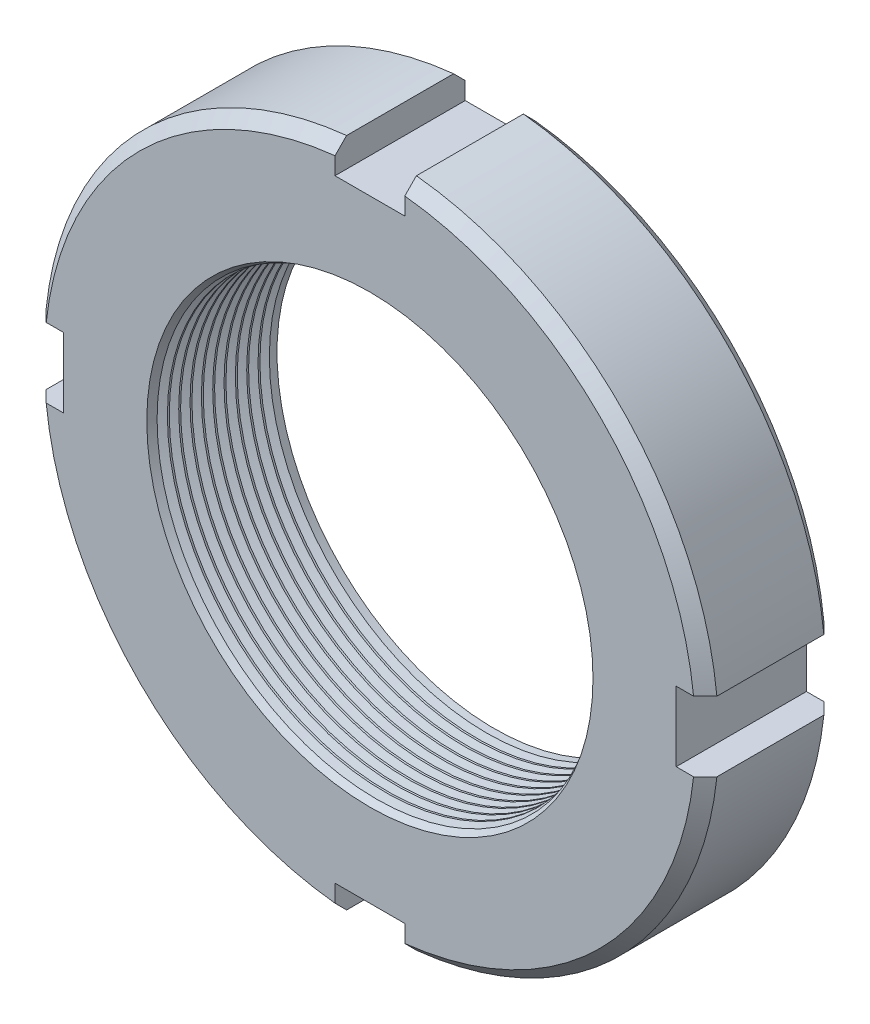
from build123d import *

# Parameters (mm, degrees)
SKETCH2_R               = 29
BASENUT_DEPTH           = 11.2
CHAMFER1_SIZE           = 1
SKETCH3_R               = 18.688
HOLE_DEPTH              = 12.2
ENDCHAMFER_SIZE2        = 0.5
ENDCHAMFER_SIZE         = 0.866025404
ENDCHAMFER_EDGE_2_SIZE2 = 0.5
ENDCHAMFER_EDGE_2_SIZE  = 0.866025404
SLOTCUT_DEPTH           = 12.2
SLOTPAT_COUNT           = 4
LPATTERN10_COUNT        = 10
LPATTERN10_PITCH        = 0.9744


with BuildPart() as part:
    # Sketch2 → BaseNut (new body)
    with BuildSketch(Plane.XY):
        Circle(SKETCH2_R)
    extrude(amount=-BASENUT_DEPTH)

    # Chamfer1
    chamfer1_edges = [part.edges().sort_by_distance(p)[0] for p in [
        (-29, 0, 0),
        (-29, 0, -11.2),
    ]]
    chamfer(chamfer1_edges, length=CHAMFER1_SIZE)

    # Sketch3 → Hole (cut, through all)
    with BuildSketch(Plane(origin=(-17.561722019, 31.682666601, 0), x_dir=(1, 0, 0), z_dir=(0, 0, 1))):
        with Locations((17.561722019, -31.682666601)):
            Circle(SKETCH3_R)
    extrude(amount=-HOLE_DEPTH, mode=Mode.SUBTRACT)

    # EndChamfer
    endchamfer_edges = [part.edges().sort_by_distance(p)[0] for p in [
        (-18.688, 0, -11.2),
    ]]
    chamfer(endchamfer_edges, length=ENDCHAMFER_SIZE, length2=ENDCHAMFER_SIZE2)

    # EndChamfer edge 2
    endchamfer_edge_2_edges = [part.edges().sort_by_distance(p)[0] for p in [
        (-18.688, 0, 0),
    ]]
    chamfer(endchamfer_edge_2_edges, length=ENDCHAMFER_EDGE_2_SIZE, length2=ENDCHAMFER_EDGE_2_SIZE2)

    # Sketch4 → SlotCut (cut, through all)
    with BuildSketch(Plane(origin=(-28.84840977, 49.266341409, 0), x_dir=(1, 0, 0), z_dir=(0, 0, 1))):
        with BuildLine():
            Line((25.84840977, -20.421931205), (25.84840977, -22.921931205))
            Line((25.84840977, -22.921931205), (31.84840977, -22.921931205))
            Line((31.84840977, -22.921931205), (31.84840977, -20.421931205))
            ThreePointArc((31.84840977, -20.421931205), (28.84840977, -20.266341409), (25.84840977, -20.421931205))
        make_face()
    slotcut = extrude(amount=-SLOTCUT_DEPTH, mode=Mode.SUBTRACT)

    # SlotPat: SlotCut ×4 about axis
    slotpat_axis = Axis((0, 0, 0), (0, 0, 1))
    for i in range(1, SLOTPAT_COUNT):
        add(slotcut.rotate(slotpat_axis, i * 360 / SLOTPAT_COUNT), mode=Mode.SUBTRACT)

    # Sketch5 → Cut-Revolve10 (revolve, cut)
    with BuildSketch(Plane(origin=(0, 0, 0), x_dir=(1, 0, 0), z_dir=(0, 1, 0))):
        Polygon((17.876, 1.272025404), (17.876, 0.460025404), (18.688, 0.460025404), (19.391212628, 0.866025404), (18.688, 1.272025404), align=None)
    cut_revolve10 = revolve(axis=Axis((0, 0, -37.301805437), (0, 0, 1)), mode=Mode.SUBTRACT)

    # LPattern10: Cut-Revolve10 ×10
    with Locations(*[(0, 0, -i * LPATTERN10_PITCH) for i in range(1, LPATTERN10_COUNT)]):
        add(cut_revolve10, mode=Mode.SUBTRACT)


solid = part.part
